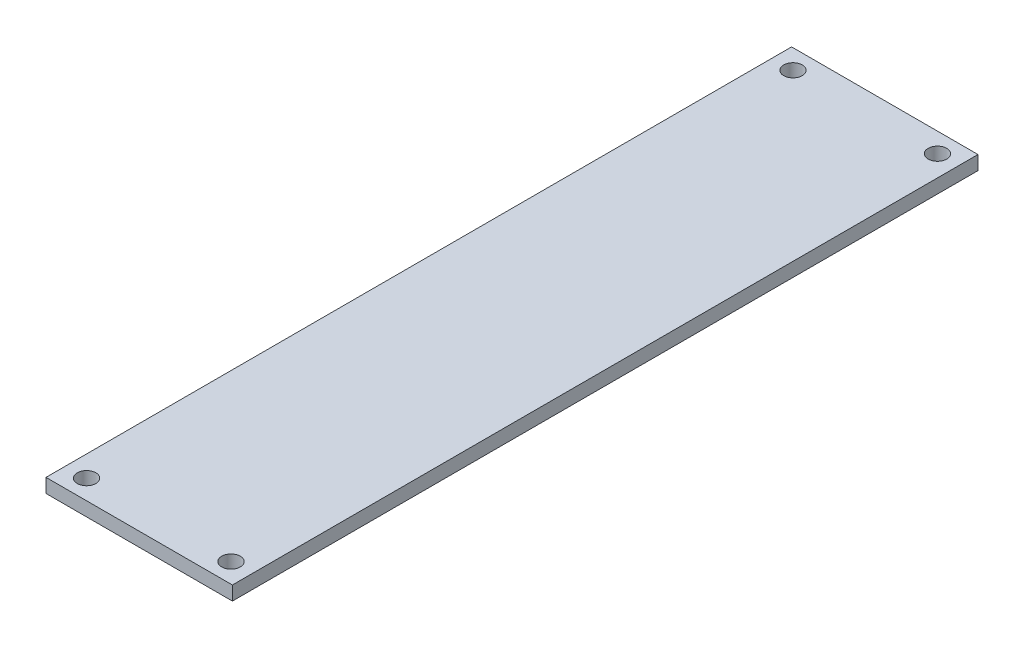
from build123d import *

# Parameters (mm, degrees)
SKETCH1_W           = 20
SKETCH1_H           = 80
BOSS_EXTRUDE1_DEPTH = 1.5
SKETCH2_R           = 1
CUT_EXTRUDE1_DEPTH  = 2.5


with BuildPart() as part:
    # Sketch1 → Boss-Extrude1 (new body)
    with BuildSketch(Plane(origin=(0, 0, 0), x_dir=(1, 0, 0), z_dir=(0, 1, 0))):
        with Locations((10, 40)):
            Rectangle(SKETCH1_W, SKETCH1_H)
    extrude(amount=BOSS_EXTRUDE1_DEPTH)

    # Sketch2 → Cut-Extrude1 (cut, through all)
    with BuildSketch(Plane(origin=(0, 1.5, 0), x_dir=(1, 0, 0), z_dir=(0, 1, 0))):
        with Locations((2.25, 77.9)):
            Circle(SKETCH2_R)
        with Locations((17.75, 77.9)):
            Circle(SKETCH2_R)
        with Locations((2.25, 2.1)):
            Circle(SKETCH2_R)
        with Locations((17.75, 2.1)):
            Circle(SKETCH2_R)
    extrude(amount=-CUT_EXTRUDE1_DEPTH, mode=Mode.SUBTRACT)


solid = part.part
